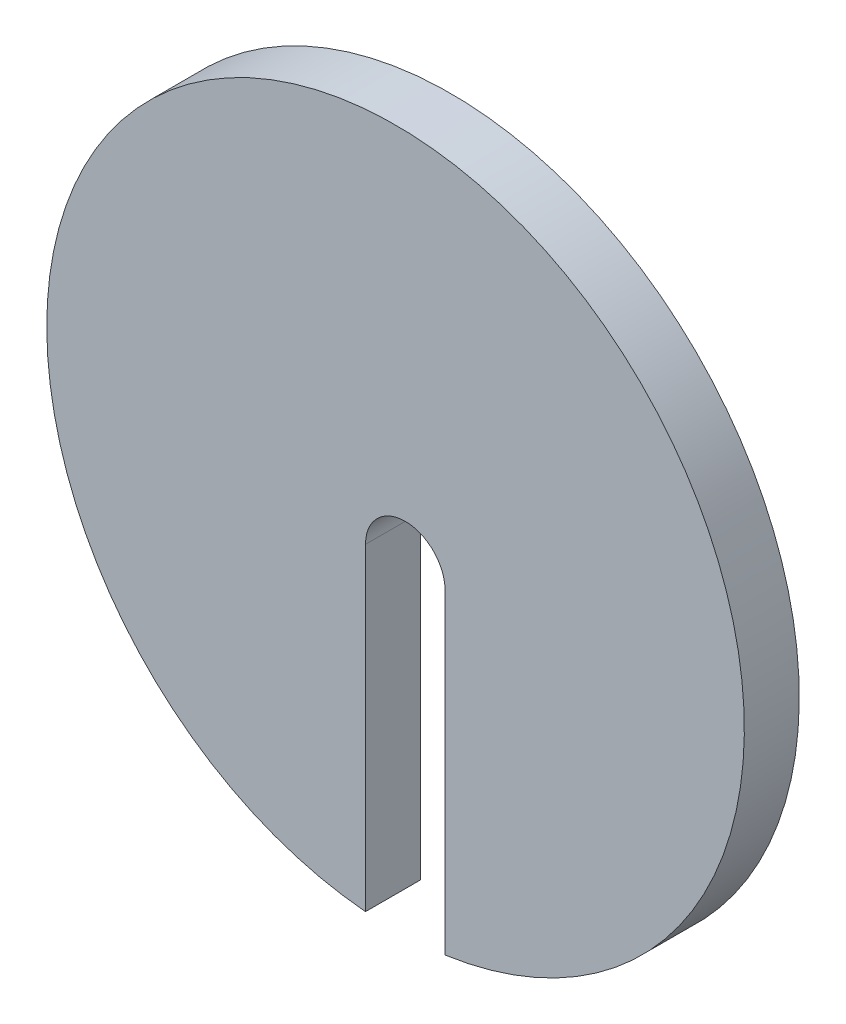
from build123d import *

# Parameters (mm, degrees)
SKETCH1_R           = 63.5
BOSS_EXTRUDE1_DEPTH = 10
CUT_EXTRUDE1_DEPTH  = 10


with BuildPart() as part:
    # Sketch1 → Boss-Extrude1 (new body)
    with BuildSketch(Plane.XY):
        Circle(SKETCH1_R)
    extrude(amount=BOSS_EXTRUDE1_DEPTH)

    # Sketch2 → Cut-Extrude1 (cut)
    with BuildSketch(Plane.XY.offset(10)):
        with BuildLine():
            Line((-5.46938567, -63.26401679), (-5.46938567, -5.342617738))
            ThreePointArc((-5.46938567, -5.342617738), (1.773678457, 1.900446389), (9.016742583, -5.342617738))
            Line((9.016742583, -5.342617738), (9.016742583, -62.85656969))
            ThreePointArc((9.016742583, -62.85656969), (1.971752502, -70.102498286), (-5.46938567, -63.26401679))
        make_face()
    extrude(amount=-CUT_EXTRUDE1_DEPTH, mode=Mode.SUBTRACT)


solid = part.part
